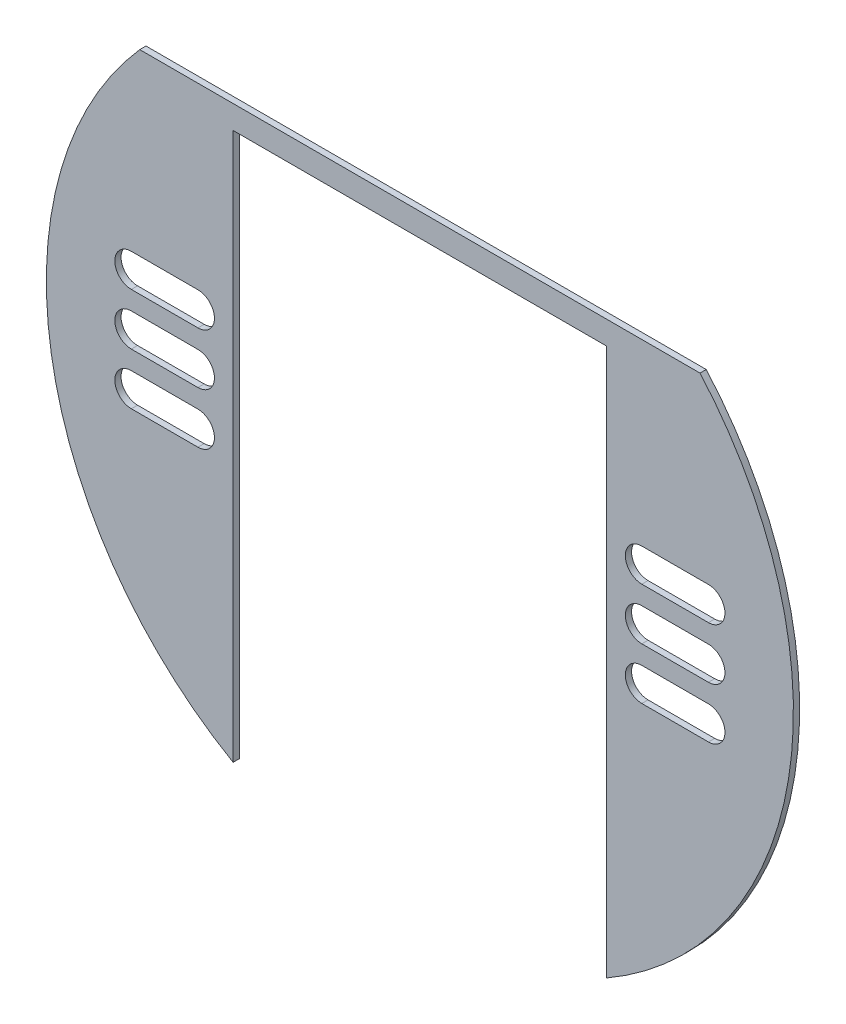
from build123d import *

# Parameters (mm, degrees)
BOSS_EXTRUDE2_DEPTH = 1


with BuildPart() as part:
    # Sketch1 → Boss-Extrude2 (new body)
    with BuildSketch(Plane.XY):
        with BuildLine():
            Line((-30, -13.100406207), (-30, -101))
            ThreePointArc((-30, -101), (-59.212156956, -58.729733103), (-45, -9.352206107))
            Line((-45, -9.352206107), (45, -9.352206107))
            ThreePointArc((45, -9.352206107), (59.212156956, -58.729733103), (30, -101))
            Line((30, -101), (30, -13.100406207))
            Line((30, -13.100406207), (-30, -13.100406207))
        make_face()
        with BuildLine():
            Line((-35.65, -43.388475773), (-46.35, -43.388475773))
            ThreePointArc((-46.35, -43.388475773), (-49, -40.738475773), (-46.35, -38.088475773))
            Line((-46.35, -38.088475773), (-35.65, -38.088475773))
            ThreePointArc((-35.65, -38.088475773), (-33, -40.738475773), (-35.65, -43.388475773))
        make_face(mode=Mode.SUBTRACT)
        with BuildLine():
            Line((-35.65, -51.688475773), (-46.35, -51.688475773))
            ThreePointArc((-46.35, -51.688475773), (-49, -49.038475773), (-46.35, -46.388475773))
            Line((-46.35, -46.388475773), (-35.65, -46.388475773))
            ThreePointArc((-35.65, -46.388475773), (-33, -49.038475773), (-35.65, -51.688475773))
        make_face(mode=Mode.SUBTRACT)
        with BuildLine():
            Line((-35.65, -59.988475773), (-46.35, -59.988475773))
            ThreePointArc((-46.35, -59.988475773), (-49, -57.338475773), (-46.35, -54.688475773))
            Line((-46.35, -54.688475773), (-35.65, -54.688475773))
            ThreePointArc((-35.65, -54.688475773), (-33, -57.338475773), (-35.65, -59.988475773))
        make_face(mode=Mode.SUBTRACT)
        with BuildLine():
            Line((46.35, -43.388475773), (35.65, -43.388475773))
            ThreePointArc((35.65, -43.388475773), (33, -40.738475773), (35.65, -38.088475773))
            Line((35.65, -38.088475773), (46.35, -38.088475773))
            ThreePointArc((46.35, -38.088475773), (49, -40.738475773), (46.35, -43.388475773))
        make_face(mode=Mode.SUBTRACT)
        with BuildLine():
            Line((46.35, -51.688475773), (35.65, -51.688475773))
            ThreePointArc((35.65, -51.688475773), (33, -49.038475773), (35.65, -46.388475773))
            Line((35.65, -46.388475773), (46.35, -46.388475773))
            ThreePointArc((46.35, -46.388475773), (49, -49.038475773), (46.35, -51.688475773))
        make_face(mode=Mode.SUBTRACT)
        with BuildLine():
            Line((46.35, -59.988475773), (35.65, -59.988475773))
            ThreePointArc((35.65, -59.988475773), (33, -57.338475773), (35.65, -54.688475773))
            Line((35.65, -54.688475773), (46.35, -54.688475773))
            ThreePointArc((46.35, -54.688475773), (49, -57.338475773), (46.35, -59.988475773))
        make_face(mode=Mode.SUBTRACT)
    extrude(amount=BOSS_EXTRUDE2_DEPTH)


solid = part.part
